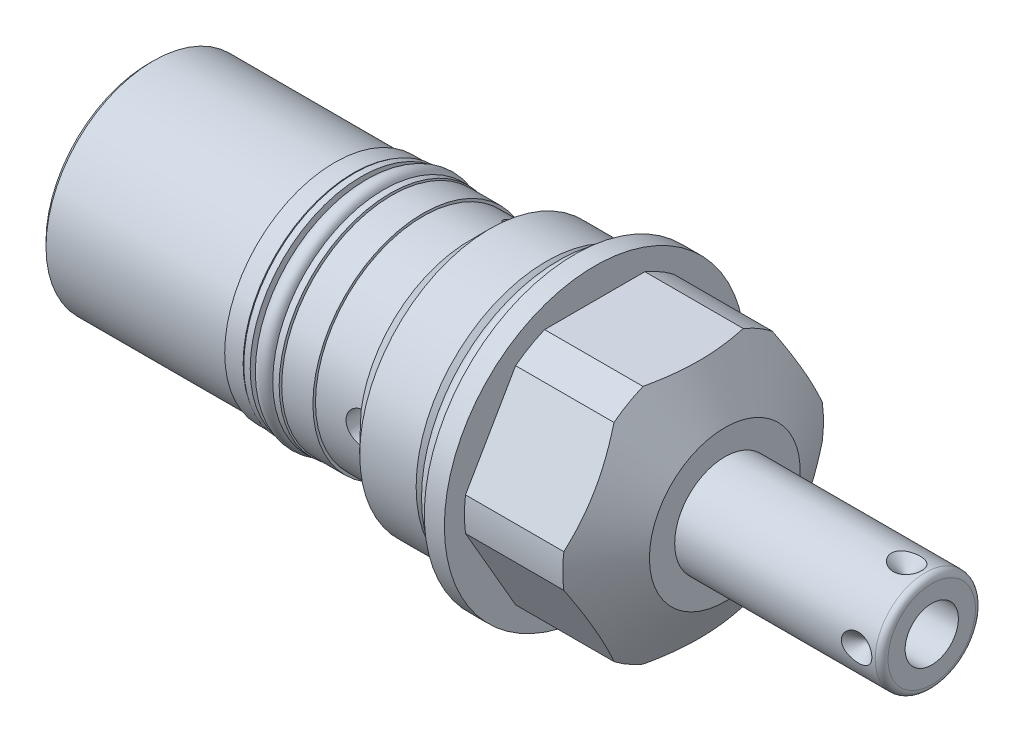
from build123d import *

# Parameters (mm, degrees)
SKETCH1_R           = 23.8125
EXTRUDE1_DEPTH      = 23.7744
EXTRUDE1_DEPTH_BACK = 67.4624
CUT_EXTRUDE1_REACH  = 69.462
SKETCH2_R           = 23.8125
SKETCH2_R_2         = 20.6375
CUT_EXTRUDE3_REACH  = 22.599
SKETCH5_R           = 23.8125
CUT_EXTRUDE5_START  = -15.576741
SKETCH7_R           = 23.8125
SKETCH7_R_2         = 20.6375
CUT_EXTRUDE5_DEPTH  = 15.576741
SKETCH12_W          = 6.1087
SKETCH12_H          = 2.032
SKETCH14_W          = 0.4064
SKETCH14_H          = 29.464
SKETCH14_H_2        = 7.4168
SKETCH15_R          = 1.4986
SKETCH16_W          = 2.1844
SKETCH16_H          = 1.016
SKETCH17_R          = 1.3081
CIRPATTERN1_COUNT   = 4
CHAMFER1_SIZE       = 0.762
SKETCH23_R          = 2.5273
CUT_EXTRUDE7_DEPTH  = 24.8125
SKETCH25_R          = 13.0302
EXTRUDE2_DEPTH      = 0.508
SKETCH26_R          = 6.1849
CUT_EXTRUDE8_DEPTH  = 0.508
CIRPATTERN2_COUNT   = 3


with BuildPart() as part:
    # Sketch1 → Extrude1 (new body, two sides)
    with BuildSketch(Plane(origin=(0, 0, 0), x_dir=(0, 0, -1), z_dir=(1, 0, 0))) as extrude1_sk:
        Circle(SKETCH1_R)
    extrude(amount=EXTRUDE1_DEPTH)
    extrude(extrude1_sk.sketch, amount=-EXTRUDE1_DEPTH_BACK)

    # Sketch2 → Cut-Extrude1 (cut, up to next)
    with BuildSketch(Plane(origin=(0, 0, 0), x_dir=(0, 0, -1), z_dir=(1, 0, 0)), mode=Mode.PRIVATE) as cut_extrude1_sk1:
        Circle(SKETCH2_R)
        Circle(SKETCH2_R_2, mode=Mode.SUBTRACT)
    cut_extrude1_tool1 = extrude(cut_extrude1_sk1.sketch, amount=-CUT_EXTRUDE1_REACH, mode=Mode.PRIVATE) & part.part
    add(cut_extrude1_tool1.solids().sort_by_distance((0, 0, 23.138981))[0], mode=Mode.SUBTRACT)

    # Sketch3 → Cut-Revolve1 (revolve, cut)
    with BuildSketch(Plane.XY, mode=Mode.PRIVATE) as cut_revolve1_sk:
        Polygon((16.918654229, 23.8125), (23.7744, 11.938), (23.7744, 23.8125), align=None)
    revolve(cut_revolve1_sk.sketch.rotate(Axis((-8.14577342, 0, 0), (1, 0, 0)), 270), axis=Axis((-8.14577342, 0, 0), (1, 0, 0)), mode=Mode.SUBTRACT)  # turned: the seam where the file's is

    # Cut-Extrude3: up to this cone (the profile starts inside it)
    cut_extrude3_end = Plane(origin=(3.175, 0, 0), z_dir=(-1, 0, 0)).offset(-27.491806514) * Cone(1.732e-06, 170.10127155, 98.208013919, align=(Align.CENTER, Align.CENTER, Align.MIN), mode=Mode.PRIVATE)
    # Sketch5 → Cut-Extrude3 (cut, up to the surface)
    with BuildSketch(Plane.ZY.offset(-3.175), mode=Mode.PRIVATE) as cut_extrude3_sk1:
        with Locations(Location((0, 0, 0), (0, 0, 180))):  # turned: the seam where the file's is
            Circle(SKETCH5_R)
        Polygon((-10.998522628, 19.05), (10.998522628, 19.05), (21.997045256, 0), (10.998522628, -19.05), (-10.998522628, -19.05), (-21.997045256, 0), align=None, mode=Mode.SUBTRACT)
    cut_extrude3_tool1 = extrude(cut_extrude3_sk1.sketch, amount=-CUT_EXTRUDE3_REACH, mode=Mode.PRIVATE) & cut_extrude3_end
    add(cut_extrude3_tool1.solids().sort_by_distance((3.175, 0, 23.138981))[0], mode=Mode.SUBTRACT)

    # Sketch7 → Cut-Extrude5 (cut)
    with BuildSketch(Plane.ZY.offset(-3.175).offset(CUT_EXTRUDE5_START)):
        with Locations(Location((0, 0, 0), (0, 0, 180))):  # turned: the seam where the file's is
            Circle(SKETCH7_R)
        with Locations(Location((0, 0, 0), (0, 0, 180))):  # turned: the seam where the file's is
            Circle(SKETCH7_R_2, mode=Mode.SUBTRACT)
    extrude(amount=CUT_EXTRUDE5_DEPTH, mode=Mode.SUBTRACT)

    # Sketch9 → Cut-Revolve3 (revolve, cut)
    with BuildSketch(Plane.XY, mode=Mode.PRIVATE) as cut_revolve3_sk:
        Polygon((0, 20.6375), (0, 19.1389), (-2.9718, 19.1389), (-4.4704, 20.6375), align=None)
    revolve(cut_revolve3_sk.sketch.rotate(Axis((-4.4205525, 0, 0), (1, 0, 0)), 90), axis=Axis((-4.4205525, 0, 0), (1, 0, 0)), mode=Mode.SUBTRACT)  # turned: the seam where the file's is

    # Sketch10 → Cut-Revolve4 (revolve, cut)
    with BuildSketch(Plane.XY, mode=Mode.PRIVATE) as cut_revolve4_sk:
        Polygon((-13.3985, 20.6375), (-16.6116, 17.4244), (-67.4624, 17.4244), (-67.4624, 20.6375), align=None)
    revolve(cut_revolve4_sk.sketch.rotate(Axis((-55.9469925, 0, 0), (1, 0, 0)), 90), axis=Axis((-55.9469925, 0, 0), (1, 0, 0)), mode=Mode.SUBTRACT)  # turned: the seam where the file's is

    # Sketch12 → Cut-Revolve6 (revolve, cut)
    with BuildSketch(Plane.XY, mode=Mode.PRIVATE) as cut_revolve6_sk:
        with Locations((-32.02305, 16.4084)):
            Rectangle(SKETCH12_W, SKETCH12_H)
    revolve(cut_revolve6_sk.sketch.rotate(Axis((-31.750635, 0, 0), (1, 0, 0)), 90), axis=Axis((-31.750635, 0, 0), (1, 0, 0)), mode=Mode.SUBTRACT)  # turned: the seam where the file's is

    # Sketch14 → Cut-Revolve8 (revolve, cut)
    with BuildSketch(Plane(origin=(0, 0, 0), x_dir=(0, -1, 0), z_dir=(0, 0, 1)), mode=Mode.PRIVATE) as cut_revolve8_sk:
        with Locations((17.2212, -52.7304)):
            Rectangle(SKETCH14_W, SKETCH14_H)
        with Locations((17.2212, -20.32)):
            Rectangle(SKETCH14_W, SKETCH14_H_2)
    revolve(cut_revolve8_sk.sketch.rotate(Axis((-55.86603, 0, 0), (1, 0, 0)), 270), axis=Axis((-55.86603, 0, 0), (1, 0, 0)), mode=Mode.SUBTRACT)  # turned: the seam where the file's is

    # Sketch16 → Revolve2 (revolve)
    with BuildSketch(Plane(origin=(0, 0, 0), x_dir=(0, -1, 0), z_dir=(0, 0, 1)), mode=Mode.PRIVATE) as revolve2_sk:
        with Locations((16.4846, -29.7307)):
            Rectangle(SKETCH16_W, SKETCH16_H)
        with Locations((16.4846, -34.3154)):
            Rectangle(SKETCH16_W, SKETCH16_H)
    revolve(revolve2_sk.sketch.rotate(Axis((-31.471235, 0, 0), (1, 0, 0)), 270), axis=Axis((-31.471235, 0, 0), (1, 0, 0)))  # turned: the seam where the file's is

    # S2D0001 → Revolve4 (revolve)
    with BuildSketch(Plane(origin=(0, 0, 0), x_dir=(0, -1, 0), z_dir=(0, 0, 1)), mode=Mode.PRIVATE) as revolve4_sk:
        with BuildLine():
            Line((0, 23.7744), (-7.9375, 23.7744))
            Line((-7.9375, 23.7744), (-7.9375, 55.5244))
            ThreePointArc((-7.9375, 55.5244), (-7.63992049, 56.24282049), (-6.9215, 56.5404))
            Line((-6.9215, 56.5404), (0, 56.5404))
            Line((0, 56.5404), (0, 23.7744))
        make_face()
    revolve(revolve4_sk.sketch.rotate(Axis((7.265766347, 0, 0), (1, 0, 0)), 90), axis=Axis((7.265766347, 0, 0), (1, 0, 0)))  # turned: the seam where the file's is

    # Sketch19 → Cut-Revolve9 (revolve, cut)
    with BuildSketch(Plane(origin=(36.322, -2.8067, 0), x_dir=(0, -1, 0), z_dir=(0, 0, 1)), mode=Mode.PRIVATE) as cut_revolve9_sk:
        Polygon((1.4097, 20.2184), (1.4097, 4.9784), (-2.8067, 2.444931286), (-2.8067, 20.2184), align=None)
    revolve(cut_revolve9_sk.sketch.rotate(Axis((17.699325537, 0, 0), (1, 0, 0)), 270), axis=Axis((17.699325537, 0, 0), (1, 0, 0)), mode=Mode.SUBTRACT)  # turned: the seam where the file's is

    # S2D0002 → Cut-Revolve10 (revolve, cut)
    with BuildSketch(Plane(origin=(32.3596, 0, -5.55625), x_dir=(1, 0, 0), z_dir=(0, 1, 0)), mode=Mode.PRIVATE) as cut_revolve10_sk:
        Polygon((20.2184, 2.38125), (22.6314, 2.38125), (20.2184, -0.03175), align=None)
    cut_revolve10 = revolve(cut_revolve10_sk.sketch.rotate(Axis((52.578, 0, -2.191027232), (0, 0, -1)), 180), axis=Axis((52.578, 0, -2.191027232), (0, 0, -1)), mode=Mode.SUBTRACT)  # turned: the seam where the file's is

    # CirPattern1: Cut-Revolve10 ×4 about axis
    cirpattern1_axis = Axis((7.265766347, 0, 0), (-1, 0, 0))
    for i in range(1, CIRPATTERN1_COUNT):
        add(cut_revolve10.rotate(cirpattern1_axis, i * 360 / CIRPATTERN1_COUNT), mode=Mode.SUBTRACT)

    # Chamfer1
    chamfer1_edges = [part.edges().sort_by_distance(p)[0] for p in [
        (-67.4624, 0, -17.018),
    ]]
    chamfer(chamfer1_edges, length=CHAMFER1_SIZE)

    # Sketch23 → Cut-Extrude7 (cut, through all)
    with BuildSketch(Plane.XY):
        with Locations(Location((-16.6624, 0, 0), (0, 0, 180))):  # turned: the seam where the file's is
            Circle(SKETCH23_R)
    cut_extrude7 = extrude(amount=CUT_EXTRUDE7_DEPTH, mode=Mode.SUBTRACT)

    # Sketch24 → Cut-Revolve11 (revolve, cut)
    with BuildSketch(Plane.XY, mode=Mode.PRIVATE) as cut_revolve11_sk:
        Polygon((-67.4624, 6.1849), (-64.9097, 5.642306865), (-64.245793135, 4.9784), (-53.1876, 4.9784), (-53.1876, 0), (-67.4624, 0), align=None)
    revolve(cut_revolve11_sk.sketch.rotate(Axis((0, 0, 0), (-1, 0, 0)), 270), axis=Axis((0, 0, 0), (-1, 0, 0)), mode=Mode.SUBTRACT)  # turned: the seam where the file's is

    # Sketch25 → Extrude2 (add)
    with BuildSketch(Plane.ZY.offset(67.4624)):
        with Locations(Location((0, 0, 0), (0, 0, 180))):  # turned: the seam where the file's is
            Circle(SKETCH25_R)
    extrude(amount=EXTRUDE2_DEPTH)

    # Sketch26 → Cut-Extrude8 (cut)
    with BuildSketch(Plane.ZY.offset(67.9704)):
        Circle(SKETCH26_R)
    extrude(amount=-CUT_EXTRUDE8_DEPTH, mode=Mode.SUBTRACT)

    # CirPattern2: Cut-Extrude7 ×3 about axis
    cirpattern2_axis = Axis((7.265766347, 0, 0), (-1, 0, 0))
    for i in range(1, CIRPATTERN2_COUNT):
        add(cut_extrude7.rotate(cirpattern2_axis, i * 360 / CIRPATTERN2_COUNT), mode=Mode.SUBTRACT)


with BuildPart() as body_2:
    # Sketch15 → Revolve1 (revolve)
    with BuildSketch(Plane(origin=(0, 0, 0), x_dir=(0, -1, 0), z_dir=(0, 0, 1)), mode=Mode.PRIVATE) as revolve1_sk:
        with Locations((20.6375, -1.4986)):
            Circle(SKETCH15_R)
    revolve(revolve1_sk.sketch.rotate(Axis((-3.09372, 0, 0), (1, 0, 0)), 270), axis=Axis((-3.09372, 0, 0), (1, 0, 0)))  # turned: the seam where the file's is


with BuildPart() as body_3:
    # Sketch17 → Revolve3 (revolve)
    with BuildSketch(Plane(origin=(0, 0, 0), x_dir=(0, -1, 0), z_dir=(0, 0, 1)), mode=Mode.PRIVATE) as revolve3_sk:
        with Locations((16.7005, -32.02305)):
            Circle(SKETCH17_R)
    revolve(revolve3_sk.sketch.rotate(Axis((-31.750635, 0, 0), (1, 0, 0)), 270), axis=Axis((-31.750635, 0, 0), (1, 0, 0)))  # turned: the seam where the file's is


solid = Compound([part.part, body_2.part, body_3.part])
